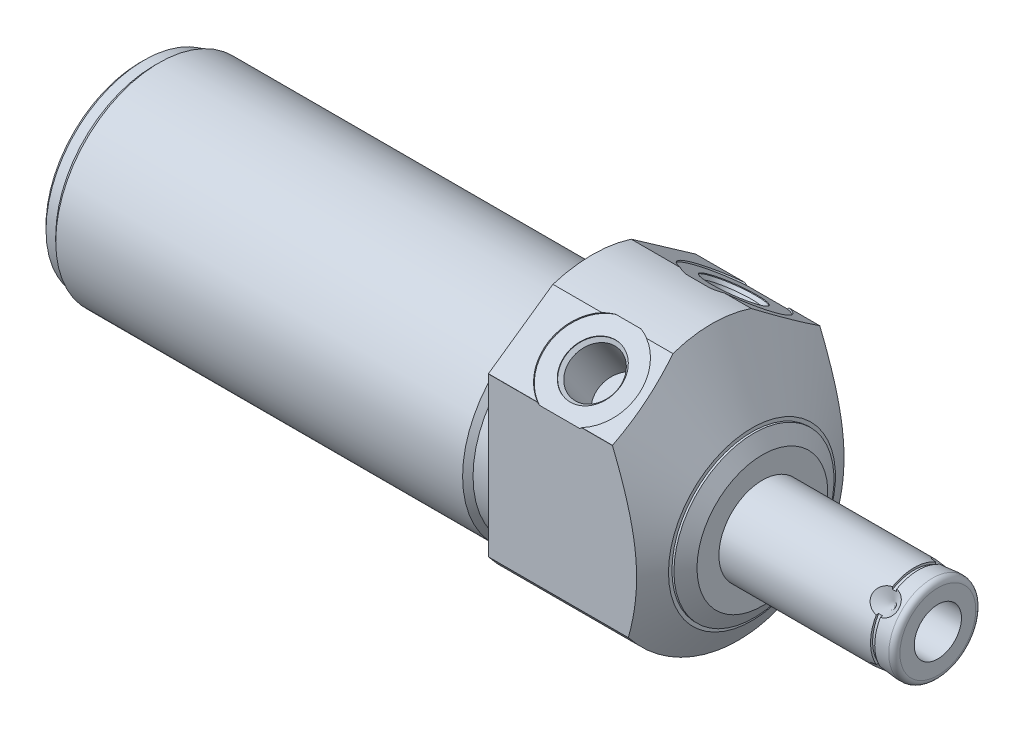
from build123d import *

# Parameters (mm, degrees)
SKETCH1_R           = 25.4
EXTRUDE1_DEPTH      = 31.0896
EXTRUDE1_DEPTH_BACK = 82.4992
CUT_EXTRUDE1_REACH  = 84.499
SKETCH2_R           = 25.4
SKETCH2_R_2         = 18.8595
CUT_EXTRUDE3_REACH  = 115.589
SKETCH4_R           = 25.4
CHAMFER1_SIZE       = 0.762
CIRPATTERN1_COUNT   = 4
SKETCH21_W          = 0.762
SKETCH21_H          = 0.381


with BuildPart() as part:
    # Sketch1 → Extrude1 (new body, two sides)
    with BuildSketch(Plane(origin=(0, 0, 0), x_dir=(0, 0, -1), z_dir=(1, 0, 0))) as extrude1_sk:
        Circle(SKETCH1_R)
    extrude(amount=EXTRUDE1_DEPTH)
    extrude(extrude1_sk.sketch, amount=-EXTRUDE1_DEPTH_BACK)

    # Sketch2 → Cut-Extrude1 (cut, up to next)
    with BuildSketch(Plane(origin=(0, 0, 0), x_dir=(0, 0, -1), z_dir=(1, 0, 0)), mode=Mode.PRIVATE) as cut_extrude1_sk1:
        Circle(SKETCH2_R)
        with Locations((0, -4.191)):
            Circle(SKETCH2_R_2, mode=Mode.SUBTRACT)
    cut_extrude1_tool1 = extrude(cut_extrude1_sk1.sketch, amount=-CUT_EXTRUDE1_REACH, mode=Mode.PRIVATE) & part.part
    add(cut_extrude1_tool1.solids().sort_by_distance((0, 0, 24.68158))[0], mode=Mode.SUBTRACT)

    # Sketch4 → Cut-Extrude3 (cut, up to next)
    with BuildSketch(Plane.ZY.offset(-31.0896), mode=Mode.PRIVATE) as cut_extrude3_sk1:
        Circle(SKETCH4_R)
        with BuildLine():
            Line((18.923, -14.455283714), (18.923, 14.455283714))
            ThreePointArc((18.923, 14.455283714), (18.914286675, 14.466682959), (18.905566483, 14.478076951))
            Line((18.905566483, 14.478076951), (7.138857516, 22.71721527))
            ThreePointArc((7.138857516, 22.71721527), (0, 23.8125), (-7.138857516, 22.71721527))
            Line((-7.138857516, 22.71721527), (-18.905566483, 14.478076951))
            ThreePointArc((-18.905566483, 14.478076951), (-18.914286675, 14.466682959), (-18.923, 14.455283714))
            Line((-18.923, 14.455283714), (-18.923, -14.455283714))
            ThreePointArc((-18.923, -14.455283714), (0, -23.8125), (18.923, -14.455283714))
        make_face(mode=Mode.SUBTRACT)
    cut_extrude3_tool1 = extrude(cut_extrude3_sk1.sketch, amount=CUT_EXTRUDE3_REACH, mode=Mode.PRIVATE) & part.part
    add(cut_extrude3_tool1.solids().sort_by_distance((31.0896, 0, -24.68158))[0], mode=Mode.SUBTRACT)

    # Sketch6 → Cut-Revolve2 (revolve, cut)
    with BuildSketch(Plane.XY, mode=Mode.PRIVATE) as cut_revolve2_sk:
        Polygon((16.331372419, 33.309), (29.1846, 11.046556788), (29.1846, 10.414), (29.549806832, 10.414), (31.0896, 7.747), (31.0896, 33.309), align=None)
    revolve(cut_revolve2_sk.sketch.rotate(Axis((1.987224567, -4.191, 0), (1, 0, 0)), 90), axis=Axis((1.987224567, -4.191, 0), (1, 0, 0)), mode=Mode.SUBTRACT)  # turned: the seam where the file's is

    # S2D0002 → Cut-Revolve3 (revolve, cut)
    with BuildSketch(Plane(origin=(13.0048, 13.712414668, 8.609072086), x_dir=(0, 0.422618262, -0.906307787), z_dir=(1, 0, 0))):
        Polygon((3.058321962, 6.915149075), (6.247621871, 7.477508699), (6.203515233, 7.727649868), (-1.926072768, 6.294184161), (-0.250020557, -3.211180271), (4.102435788, -2.443724785), (2.59619413, 6.098596146), (3.080375281, 6.790078491), align=None)
    cut_revolve3 = revolve(axis=Axis((13.0048, 2.978510308, 2.074416081), (0, 0.819152044, 0.573576436)), mode=Mode.SUBTRACT)

    # Mirror1: Cut-Revolve3 across plane
    add(cut_revolve3.mirror(Plane.XY), mode=Mode.SUBTRACT)

    # Sketch10 → Cut-Revolve6 (revolve, cut)
    with BuildSketch(Plane.XY, mode=Mode.PRIVATE) as cut_revolve6_sk:
        Polygon((0, 14.6685), (0, 13.716), (-3.81, 13.716), (-4.7625, 14.6685), align=None)
    revolve(cut_revolve6_sk.sketch.rotate(Axis((-5.09397, -4.191, 0), (1, 0, 0)), 90), axis=Axis((-5.09397, -4.191, 0), (1, 0, 0)), mode=Mode.SUBTRACT)  # turned: the seam where the file's is

    # Sketch12 → Cut-Revolve8 (revolve, cut)
    with BuildSketch(Plane.XY, mode=Mode.PRIVATE) as cut_revolve8_sk:
        Polygon((-82.4992, 14.6685), (-82.4992, 13.716), (-79.9592, 13.716), (-79.0067, 14.6685), align=None)
    revolve(cut_revolve8_sk.sketch.rotate(Axis((-50.92827, -4.191, 0), (1, 0, 0)), 90), axis=Axis((-50.92827, -4.191, 0), (1, 0, 0)), mode=Mode.SUBTRACT)  # turned: the seam where the file's is

    # Chamfer1
    chamfer1_edges = [part.edges().sort_by_distance(p)[0] for p in [
        (-82.4992, -4.191, -17.907),
    ]]
    chamfer(chamfer1_edges, length=CHAMFER1_SIZE)

    # Sketch13 → Revolve1 (revolve)
    with BuildSketch(Plane.XY, mode=Mode.PRIVATE) as revolve1_sk:
        with BuildLine():
            Line((31.0896, -4.191), (63.106, -4.191))
            Line((63.106, -4.191), (63.106, -11.1125))
            ThreePointArc((63.106, -11.1125), (62.80842049, -11.83092049), (62.09, -12.1285))
            Line((62.09, -12.1285), (31.0896, -12.1285))
            Line((31.0896, -12.1285), (31.0896, -4.191))
        make_face()
    revolve(revolve1_sk.sketch.rotate(Axis((4.7498, -4.191, 0), (1, 0, 0)), 270), axis=Axis((4.7498, -4.191, 0), (1, 0, 0)))  # turned: the seam where the file's is

    # S2D0001 → Cut-Revolve9 (revolve, cut)
    with BuildSketch(Plane.XY, mode=Mode.PRIVATE) as cut_revolve9_sk:
        Polygon((63.106, 0.1143), (47.866, 0.1143), (45.279114777, -4.191), (63.106, -4.191), align=None)
    revolve(cut_revolve9_sk.sketch.rotate(Axis((-2.8067, -4.191, 0), (-1, 0, 0)), 270), axis=Axis((-2.8067, -4.191, 0), (-1, 0, 0)), mode=Mode.SUBTRACT)  # turned: the seam where the file's is

    # Sketch16 → Cut-Revolve10 (revolve, cut)
    with BuildSketch(Plane(origin=(0, -7.15448452, 2.96348452), x_dir=(1, 0, 0), z_dir=(0, -0.707106781, -0.707106781)), mode=Mode.PRIVATE) as cut_revolve10_sk:
        Polygon((59.1436, -12.1285), (56.7306, -12.1285), (59.1436, -9.7155), align=None)
    cut_revolve10 = revolve(cut_revolve10_sk.sketch.rotate(Axis((59.1436, -4.694604004, 0.503604004), (0, -0.707106781, 0.707106781)), 270), axis=Axis((59.1436, -4.694604004, 0.503604004), (0, -0.707106781, 0.707106781)), mode=Mode.SUBTRACT)  # turned: the seam where the file's is

    # CirPattern1: Cut-Revolve10 ×4 about axis
    cirpattern1_axis = Axis((4.7498, -4.191, 0), (-1, 0, 0))
    for i in range(1, CIRPATTERN1_COUNT):
        add(cut_revolve10.rotate(cirpattern1_axis, i * 360 / CIRPATTERN1_COUNT), mode=Mode.SUBTRACT)

    # Sketch21 → Cut-Revolve11 (revolve, cut)
    with BuildSketch(Plane.XY, mode=Mode.PRIVATE) as cut_revolve11_sk:
        with Locations((59.1436, 3.556)):
            Rectangle(SKETCH21_W, SKETCH21_H)
    revolve(cut_revolve11_sk.sketch.rotate(Axis((23.873488058, -4.191, 0), (1, 0, 0)), 90), axis=Axis((23.873488058, -4.191, 0), (1, 0, 0)), mode=Mode.SUBTRACT)  # turned: the seam where the file's is


solid = part.part
